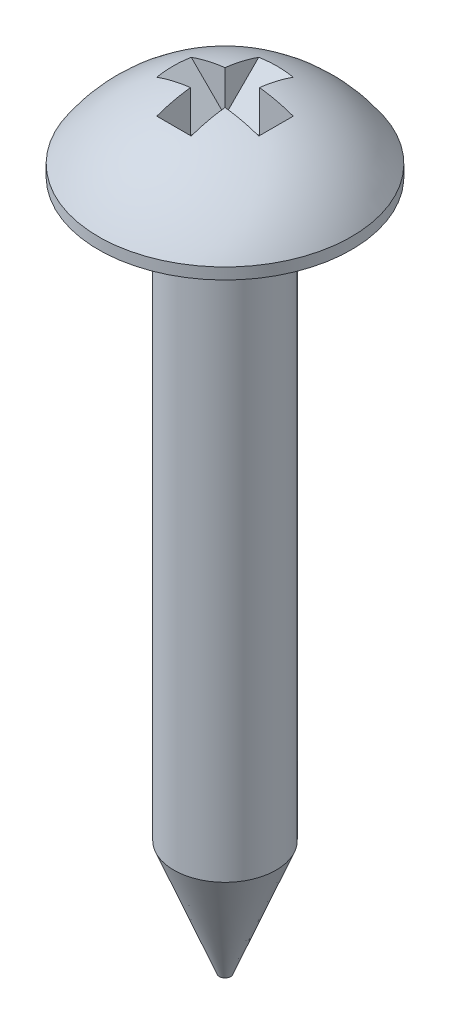
from build123d import *

# Parameters (mm, degrees)
CUT_EXTRUDE1_DEPTH = 0.381
CIRPATTERN1_COUNT  = 2
CIRPATTERN1_ANGLE  = 90


with BuildPart() as part:
    # Sketch1 → Revolve1 (revolve)
    with BuildSketch(Plane.XY):
        with BuildLine():
            Line((2.794, 0.25), (2.794, 0))
            Line((2.794, 0), (1.13, 0))
            Line((1.13, 0), (1.13, -12.7))
            Line((1.13, -12.7), (0.125, -15.24))
            Line((0.125, -15.24), (0, -15.24))
            Line((0, -15.24), (0, 1.75))
            ThreePointArc((0, 1.75), (1.58559421, 1.351288149), (2.794, 0.25))
        make_face()
    revolve(axis=Axis((0, 0, 0), (0, 1, 0)))

    # Sketch2 → Cut-Extrude1 (cut, symmetric)
    with BuildSketch(Plane.XY):
        Polygon((-1.8, 2.20611304), (-0.381, 0.78711304), (0.381, 0.78711304), (1.8, 2.20611304), align=None)
    cut_extrude1 = extrude(amount=CUT_EXTRUDE1_DEPTH, both=True, mode=Mode.SUBTRACT)

    # CirPattern1: Cut-Extrude1 ×2 about axis
    cirpattern1_axis = Axis((0, 50, 0), (0, -1, 0))
    for i in range(1, CIRPATTERN1_COUNT):
        add(cut_extrude1.rotate(cirpattern1_axis, i * CIRPATTERN1_ANGLE / (CIRPATTERN1_COUNT - 1)), mode=Mode.SUBTRACT)


solid = part.part
